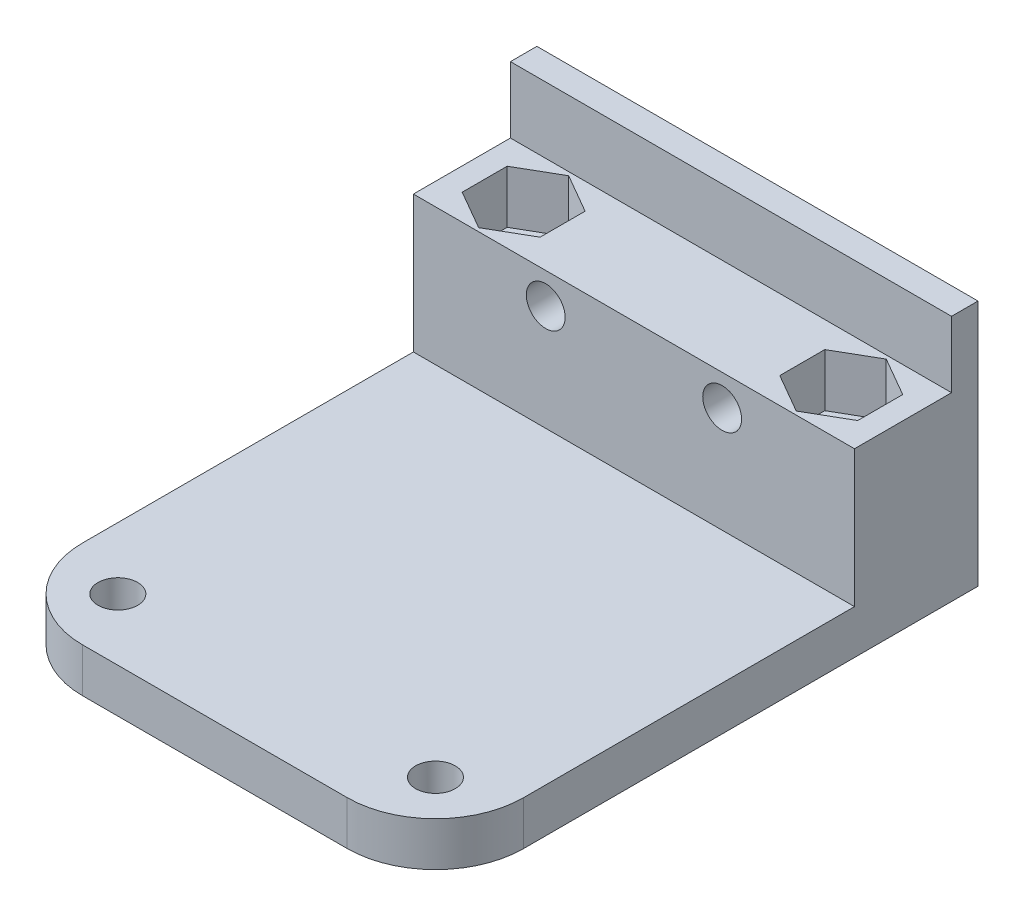
from build123d import *

# Parameters (mm, degrees)
SKETCH1_W               = 50
SKETCH1_H               = 33
BOSS_EXTRUDE1_DEPTH     = 3
SKETCH2_W               = 50
SKETCH2_H               = 5
BOSS_EXTRUDE2_DEPTH     = 58.5
SKETCH6_W               = 50
SKETCH6_H               = 5
CUT_EXTRUDE3_DEPTH      = 3
SKETCH7_W               = 50
SKETCH7_H               = 11
BOSS_EXTRUDE4_DEPTH     = 15.5
CUT_EXTRUDE4_DEPTH      = 6
SKETCH4_R               = 2.2
CUT_EXTRUDE5_DEPTH      = 59.5
SKETCH3_R               = 2.2479
CUT_EXTRUDE1_DEPTH      = 24
CUT_EXTRUDE1_DEPTH_BACK = 6


with BuildPart() as part:
    # Sketch1 → Boss-Extrude1 (new body)
    with BuildSketch(Plane.XY):
        Rectangle(SKETCH1_W, SKETCH1_H)
    extrude(amount=BOSS_EXTRUDE1_DEPTH)

    # Sketch2 → Boss-Extrude2 (add)
    with BuildSketch(Plane.XY.offset(3)):
        with Locations((0, -14)):
            Rectangle(SKETCH2_W, SKETCH2_H)
    extrude(amount=BOSS_EXTRUDE2_DEPTH)

    # Sketch6 → Cut-Extrude3 (cut)
    with BuildSketch(Plane.XY.offset(3)):
        with Locations((0, 14)):
            Rectangle(SKETCH6_W, SKETCH6_H)
    extrude(amount=-CUT_EXTRUDE3_DEPTH, mode=Mode.SUBTRACT)

    # Sketch7 → Boss-Extrude4 (add)
    with BuildSketch(Plane(origin=(0, -11.5, 0), x_dir=(1, 0, 0), z_dir=(0, 1, 0))):
        with Locations((0, -8.5)):
            Rectangle(SKETCH7_W, SKETCH7_H)
    extrude(amount=BOSS_EXTRUDE4_DEPTH)

    # Sketch8 → Cut-Extrude4 (cut)
    with BuildSketch(Plane(origin=(0, 4, 0), x_dir=(1, 0, 0), z_dir=(0, 1, 0))):
        Polygon((-18, -3.4), (-22.416729559, -5.95), (-22.416729559, -11.05), (-18, -13.6), (-13.583270441, -11.05), (-13.583270441, -5.95), align=None)
        Polygon((13.583270441, -5.95), (18, -3.4), (22.416729559, -5.95), (22.416729559, -11.05), (18, -13.6), (13.583270441, -11.05), align=None)
    extrude(amount=-CUT_EXTRUDE4_DEPTH, mode=Mode.SUBTRACT)

    # Sketch4 → Cut-Extrude5 (cut, through all)
    with BuildSketch(Plane.XY.offset(3)):
        with Locations((-10.000570114, 0.5)):
            Circle(SKETCH4_R)
        with Locations((9.999429886, 0.5)):
            Circle(SKETCH4_R)
    extrude(amount=CUT_EXTRUDE5_DEPTH, mode=Mode.SUBTRACT)

    # Sketch3 → Cut-Extrude1 (cut, two sides)
    with BuildSketch(Plane(origin=(0, -11.5, 0), x_dir=(1, 0, 0), z_dir=(0, 1, 0))) as cut_extrude1_sk:
        with Locations((-18, -54.5)):
            Circle(SKETCH3_R)
        with Locations((18, -54.5)):
            Circle(SKETCH3_R)
        with Locations((-18, -8.5)):
            Circle(SKETCH3_R)
        with Locations((18, -8.5)):
            Circle(SKETCH3_R)
        with BuildLine():
            Line((-25, -51.5), (-25, -61.5))
            Line((-25, -61.5), (-15, -61.5))
            ThreePointArc((-15, -61.5), (-22.071067812, -58.571067812), (-25, -51.5))
        make_face()
        with BuildLine():
            Line((15, -61.5), (25, -61.5))
            Line((25, -61.5), (25, -51.5))
            ThreePointArc((25, -51.5), (22.071067812, -58.571067812), (15, -61.5))
        make_face()
    extrude(amount=CUT_EXTRUDE1_DEPTH, mode=Mode.SUBTRACT)
    extrude(cut_extrude1_sk.sketch, amount=-CUT_EXTRUDE1_DEPTH_BACK, mode=Mode.SUBTRACT)


solid = part.part
